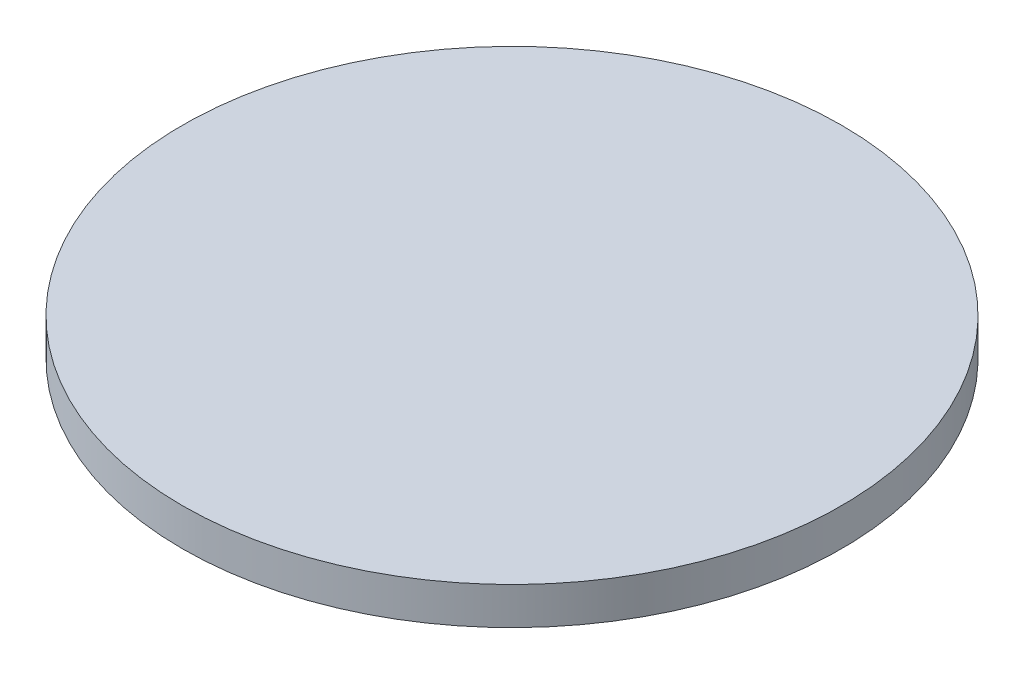
from build123d import *

# Parameters (mm, degrees)
SKETCH_1_R      = 15
EXTRUDE_1_DEPTH = 1.7


with BuildPart() as part:
    # 草图1 → 凸台-拉伸1 (new body)
    with BuildSketch(Plane(origin=(0, 0, 0), x_dir=(1, 0, 0), z_dir=(0, 1, 0))):
        Circle(SKETCH_1_R)
    extrude(amount=EXTRUDE_1_DEPTH)


solid = part.part
